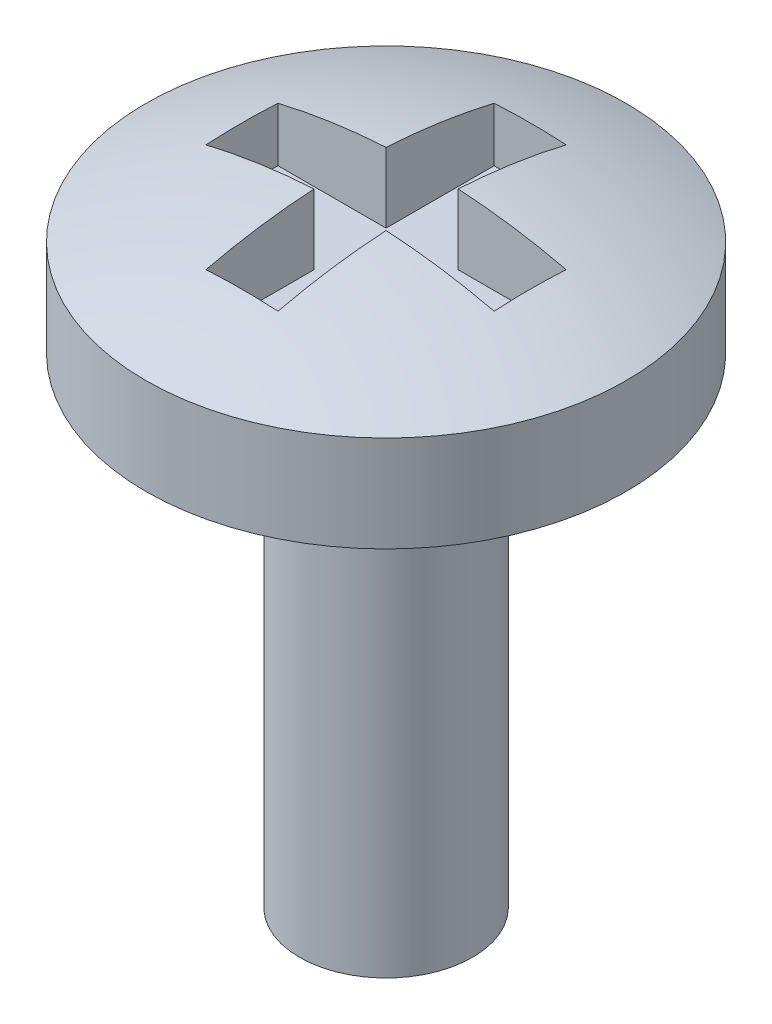
from build123d import *

# Parameters (mm, degrees)
SKETCH1_R           = 0.9
BOSS_EXTRUDE1_DEPTH = 5
SKETCH2_R           = 2.5
BOSS_EXTRUDE2_DEPTH = 1
DOME1_FACE_RADIUS   = 2.5
DOME1_HEIGHT        = 0.5
SKETCH3_W           = 1.125
SKETCH3_H           = 0.75
SKETCH3_W_2         = 0.75
SKETCH3_H_2         = 1.125
CUT_EXTRUDE1_DEPTH  = 0.75


with BuildPart() as part:
    # Sketch1 → Boss-Extrude1 (new body)
    with BuildSketch(Plane(origin=(0, 0, 0), x_dir=(1, 0, 0), z_dir=(0, 1, 0))):
        Circle(SKETCH1_R)
    extrude(amount=BOSS_EXTRUDE1_DEPTH)

    # Sketch2 → Boss-Extrude2 (add)
    with BuildSketch(Plane(origin=(0, 5, 0), x_dir=(1, 0, 0), z_dir=(0, 1, 0))):
        Circle(SKETCH2_R)
    extrude(amount=BOSS_EXTRUDE2_DEPTH)

    # Dome1: a dome of height H over a round flat face of radius A is a cap of a sphere of radius (A * A + H * H) / (2 * H)
    dome1_r = (DOME1_FACE_RADIUS * DOME1_FACE_RADIUS + DOME1_HEIGHT * DOME1_HEIGHT) / (2 * DOME1_HEIGHT)
    dome1_base = Plane((0, 6, 0), z_dir=(0, 1, 0))
    with Locations(dome1_base.offset(DOME1_HEIGHT - dome1_r)):
        dome1_ball = Sphere(dome1_r, mode=Mode.PRIVATE)
    add(split(dome1_ball, bisect_by=dome1_base, keep=Keep.TOP, mode=Mode.PRIVATE))

    # Sketch3 → Cut-Extrude1 (cut)
    with BuildSketch(Plane(origin=(0, 6.5, 0), x_dir=(1, 0, 0), z_dir=(0, 1, 0))):
        with Locations((-0.9375, 0)):
            Rectangle(SKETCH3_W, SKETCH3_H)
        Rectangle(SKETCH3_W_2, SKETCH3_H)
        with Locations((0, 0.9375)):
            Rectangle(SKETCH3_W_2, SKETCH3_H_2)
        with Locations((0.9375, 0)):
            Rectangle(SKETCH3_W, SKETCH3_H)
        with Locations((0, -0.9375)):
            Rectangle(SKETCH3_W_2, SKETCH3_H_2)
    extrude(amount=-CUT_EXTRUDE1_DEPTH, mode=Mode.SUBTRACT)


solid = part.part
